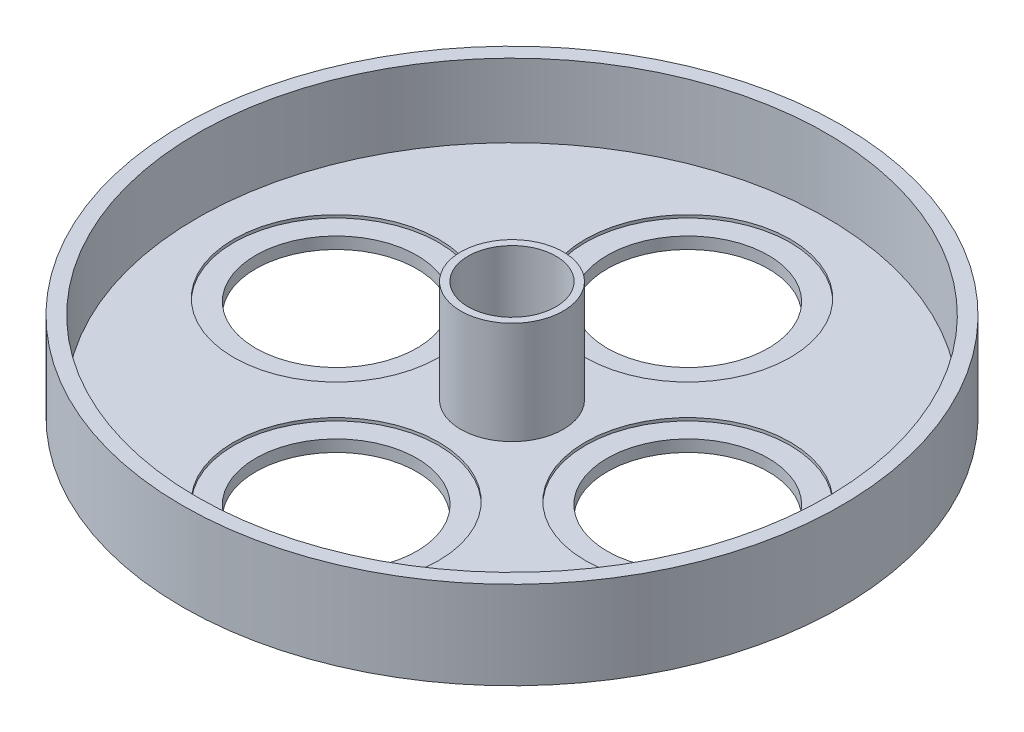
from build123d import *

# Parameters (mm, degrees)
CROQUIS1_R              = 225
CROQUIS1_R_2            = 55
CROQUIS1_R_3            = 35
SALIENTE_EXTRUIR1_DEPTH = 10
CROQUIS3_R              = 225
CROQUIS3_R_2            = 215
SALIENTE_EXTRUIR2_DEPTH = 50
CROQUIS4_R              = 70
CORTAR_EXTRUIR2_DEPTH   = 2
CROQUIS5_R              = 35
CROQUIS5_R_2            = 30
SALIENTE_EXTRUIR3_DEPTH = 70


with BuildPart() as part:
    # Croquis1 → Saliente-Extruir1 (new body)
    with BuildSketch(Plane(origin=(0, 0, 0), x_dir=(1, 0, 0), z_dir=(0, 1, 0))):
        Circle(CROQUIS1_R)
        with Locations((0, 120)):
            Circle(CROQUIS1_R_2, mode=Mode.SUBTRACT)
        Circle(CROQUIS1_R_3, mode=Mode.SUBTRACT)
        with Locations((120, 0)):
            Circle(CROQUIS1_R_2, mode=Mode.SUBTRACT)
        with Locations((0, -120)):
            Circle(CROQUIS1_R_2, mode=Mode.SUBTRACT)
        with Locations((-120, 0)):
            Circle(CROQUIS1_R_2, mode=Mode.SUBTRACT)
    extrude(amount=SALIENTE_EXTRUIR1_DEPTH)

    # Croquis3 → Saliente-Extruir2 (add)
    with BuildSketch(Plane(origin=(0, 10, 0), x_dir=(1, 0, 0), z_dir=(0, 1, 0))):
        Circle(CROQUIS3_R)
        Circle(CROQUIS3_R_2, mode=Mode.SUBTRACT)
    extrude(amount=SALIENTE_EXTRUIR2_DEPTH)

    # Croquis4 → Cortar-Extruir2 (cut)
    with BuildSketch(Plane(origin=(0, 10, 0), x_dir=(1, 0, 0), z_dir=(0, 1, 0))):
        with Locations((0, 120)):
            Circle(CROQUIS4_R)
        with Locations((120, 0)):
            Circle(CROQUIS4_R)
        with Locations((0, -120)):
            Circle(CROQUIS4_R)
        with Locations((-120, 0)):
            Circle(CROQUIS4_R)
    extrude(amount=-CORTAR_EXTRUIR2_DEPTH, mode=Mode.SUBTRACT)


with BuildPart() as body_2:
    # Croquis5 → Saliente-Extruir3 (new body)
    with BuildSketch(Plane(origin=(0, 10, 0), x_dir=(1, 0, 0), z_dir=(0, 1, 0))):
        Circle(CROQUIS5_R)
        Circle(CROQUIS5_R_2, mode=Mode.SUBTRACT)
    extrude(amount=SALIENTE_EXTRUIR3_DEPTH)


solid = Compound([part.part, body_2.part])
